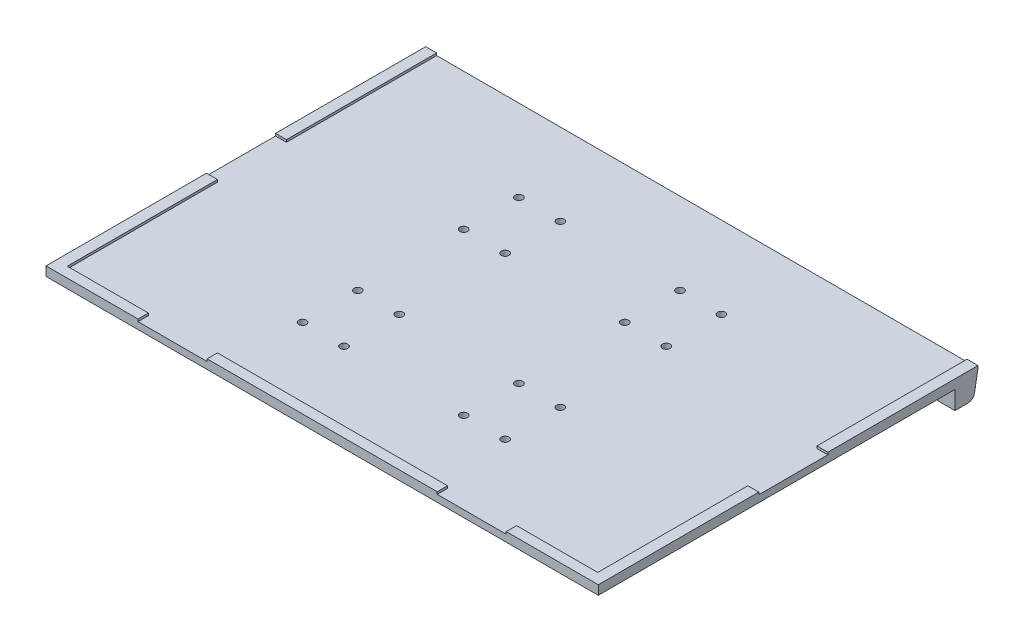
from build123d import *

# Parameters (mm, degrees)
BOSS_EXTRUDE3_DEPTH   = 4
SKETCH2_W             = 100
SKETCH2_H             = 4.5
BOSS_EXTRUDE3_2_DEPTH = 4
BOSS_EXTRUDE3_3_DEPTH = 4
SKETCH2_W_2           = 4.75
SKETCH2_H_2           = 65.25
BOSS_EXTRUDE3_4_DEPTH = 4
BOSS_EXTRUDE3_5_DEPTH = 4
SKETCH2_5_R           = 1.65
BOSS_EXTRUDE4_DEPTH   = 3
SKETCH3_W             = 240
SKETCH3_H             = 10
BOSS_EXTRUDE5_DEPTH   = 8
CUT_EXTRUDE1_DEPTH    = 254.909924973
FILLET2_R             = 3


with BuildPart() as part:
    # Sketch2 → Boss-Extrude3 (new body)
    with BuildSketch(Plane(origin=(0, 0, 0), x_dir=(1, 0, 0), z_dir=(0, 1, 0))):
        Polygon((115.25, -78), (80, -78), (80, -82.5), (120, -82.5), (120, -12.75), (115.25, -12.75), align=None)
    extrude(amount=BOSS_EXTRUDE3_DEPTH)



with BuildPart() as body_2:
    # Sketch2 → Boss-Extrude3 2 (new body)
    with BuildSketch(Plane(origin=(0, 0, 0), x_dir=(1, 0, 0), z_dir=(0, 1, 0))):
        with Locations((0, -80.25)):
            Rectangle(SKETCH2_W, SKETCH2_H)
    extrude(amount=BOSS_EXTRUDE3_2_DEPTH)


with BuildPart() as body_3:
    # Sketch2 → Boss-Extrude3 3 (new body)
    with BuildSketch(Plane(origin=(0, 0, 0), x_dir=(1, 0, 0), z_dir=(0, 1, 0))):
        Polygon((-80, -82.5), (-80, -78), (-115.25, -78), (-115.25, -12.75), (-120, -12.75), (-120, -82.5), align=None)
    extrude(amount=BOSS_EXTRUDE3_3_DEPTH)


with BuildPart() as body_4:
    # Sketch2 → Boss-Extrude3 4 (new body)
    with BuildSketch(Plane(origin=(0, 0, 0), x_dir=(1, 0, 0), z_dir=(0, 1, 0))):
        with Locations((117.625, 49.875)):
            Rectangle(SKETCH2_W_2, SKETCH2_H_2)
    extrude(amount=BOSS_EXTRUDE3_4_DEPTH)


with BuildPart() as body_5:
    # Sketch2 → Boss-Extrude3 5 (new body)
    with BuildSketch(Plane(origin=(0, 0, 0), x_dir=(1, 0, 0), z_dir=(0, 1, 0))):
        with Locations((-117.625, 49.875)):
            Rectangle(SKETCH2_W_2, SKETCH2_H_2)
    extrude(amount=BOSS_EXTRUDE3_5_DEPTH)


with BuildPart() as part_1:
    add(part.part)

    add(body_2.part)  # Boss-Extrude4 merges body 2

    add(body_3.part)  # Boss-Extrude4 merges body 3

    add(body_4.part)  # Boss-Extrude4 merges body 4

    add(body_5.part)  # Boss-Extrude4 merges body 5
    # Sketch2_5 → Boss-Extrude4 (add)
    with BuildSketch(Plane(origin=(0, 0, 0), x_dir=(1, 0, 0), z_dir=(0, 1, 0))):
        Polygon((80, -82.5), (80, -78), (115.25, -78), (115.25, -12.75), (120, -12.75), (120, 17.25), (115.25, 17.25), (115.25, 82.5), (-115.25, 82.5), (-115.25, 17.25), (-120, 17.25), (-120, -12.75), (-115.25, -12.75), (-115.25, -78), (-80, -78), (-80, -82.5), (-50, -82.5), (-50, -78), (50, -78), (50, -82.5), align=None)
        with Locations((44, 47)):
            Circle(SKETCH2_5_R, mode=Mode.SUBTRACT)
        with Locations((-44, -47)):
            Circle(SKETCH2_5_R, mode=Mode.SUBTRACT)
        with Locations((-26, -47)):
            Circle(SKETCH2_5_R, mode=Mode.SUBTRACT)
        with Locations((-44, -23)):
            Circle(SKETCH2_5_R, mode=Mode.SUBTRACT)
        with Locations((-26, -23)):
            Circle(SKETCH2_5_R, mode=Mode.SUBTRACT)
        with Locations((26, -47)):
            Circle(SKETCH2_5_R, mode=Mode.SUBTRACT)
        with Locations((44, -47)):
            Circle(SKETCH2_5_R, mode=Mode.SUBTRACT)
        with Locations((26, -23)):
            Circle(SKETCH2_5_R, mode=Mode.SUBTRACT)
        with Locations((44, -23)):
            Circle(SKETCH2_5_R, mode=Mode.SUBTRACT)
        with Locations((-44, 23)):
            Circle(SKETCH2_5_R, mode=Mode.SUBTRACT)
        with Locations((-26, 23)):
            Circle(SKETCH2_5_R, mode=Mode.SUBTRACT)
        with Locations((-44, 47)):
            Circle(SKETCH2_5_R, mode=Mode.SUBTRACT)
        with Locations((-26, 47)):
            Circle(SKETCH2_5_R, mode=Mode.SUBTRACT)
        with Locations((26, 23)):
            Circle(SKETCH2_5_R, mode=Mode.SUBTRACT)
        with Locations((44, 23)):
            Circle(SKETCH2_5_R, mode=Mode.SUBTRACT)
        with Locations((26, 47)):
            Circle(SKETCH2_5_R, mode=Mode.SUBTRACT)
    extrude(amount=BOSS_EXTRUDE4_DEPTH)

    # Sketch3 → Boss-Extrude5 (add)
    with BuildSketch(Plane.XZ):
        with Locations((0, -77.5)):
            Rectangle(SKETCH3_W, SKETCH3_H)
    extrude(amount=BOSS_EXTRUDE5_DEPTH)

    # Sketch4 → Cut-Extrude1 (cut, through all)
    with BuildSketch(Plane(origin=(120, 0, 0), x_dir=(0, 0, -1), z_dir=(1, 0, 0))):
        Polygon((82.5, 3), (80.560403212, -8), (82.5, -8), align=None)
    extrude(amount=-CUT_EXTRUDE1_DEPTH, mode=Mode.SUBTRACT)

    # Fillet2
    fillet2_edges = [part_1.edges().sort_by_distance(p)[0] for p in [
        (0, -8, -80.560403212),
    ]]
    fillet(fillet2_edges, radius=FILLET2_R)


solid = part_1.part
